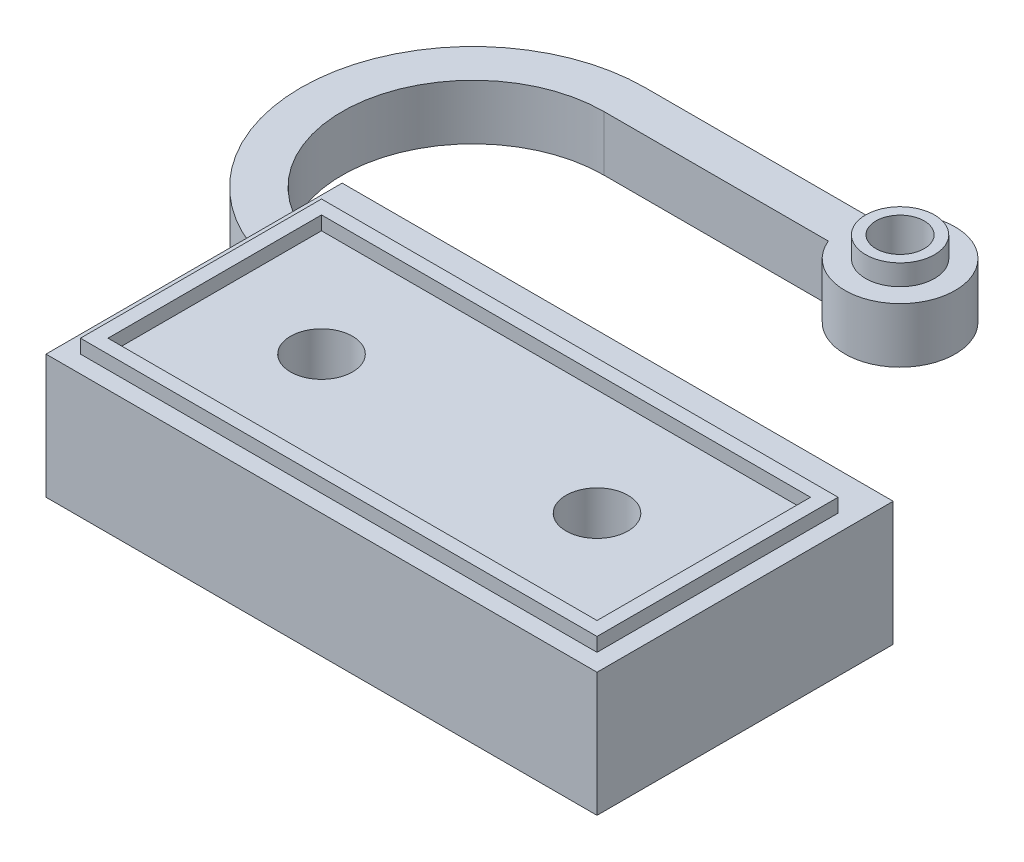
from build123d import *

# Parameters (mm, degrees)
SKETCH1_W           = 40
SKETCH1_H           = 21.5
SKETCH1_R           = 2.25
BOSS_EXTRUDE3_DEPTH = 9
SKETCH1_5_R         = 1.75
BOSS_EXTRUDE4_DEPTH = 4
SKETCH2_R           = 2.5
SKETCH2_R_2         = 1.75
BOSS_EXTRUDE5_DEPTH = 1.5
SKETCH3_W           = 37.5
SKETCH3_H           = 17.5
SKETCH3_W_2         = 35.5
SKETCH3_H_2         = 15.5
BOSS_EXTRUDE6_DEPTH = 1


with BuildPart() as part:
    # Sketch1 → Boss-Extrude3 (new body)
    with BuildSketch(Plane(origin=(0, 0, 0), x_dir=(1, 0, 0), z_dir=(0, 1, 0))):
        with Locations((0, 0.75)):
            Rectangle(SKETCH1_W, SKETCH1_H)
        with Locations((10, 0)):
            Circle(SKETCH1_R, mode=Mode.SUBTRACT)
        with Locations((-10, 0)):
            Circle(SKETCH1_R, mode=Mode.SUBTRACT)
    extrude(amount=BOSS_EXTRUDE3_DEPTH)

    # Sketch1_5 → Boss-Extrude4 (add)
    with BuildSketch(Plane(origin=(0, 0, 0), x_dir=(1, 0, 0), z_dir=(0, 1, 0))):
        with BuildLine():
            ThreePointArc((-20, 33.5), (-32.5, 21), (-20, 8.5))
            Line((-20, 8.5), (-20, 10))
            Line((-20, 10), (-20, 11.5))
            ThreePointArc((-20, 11.5), (-29.5, 21), (-20, 30.5))
            Line((-20, 30.5), (-3.708099244, 30.5))
            ThreePointArc((-3.708099244, 30.5), (4, 32), (-3.708099244, 33.5))
            Line((-3.708099244, 33.5), (-20, 33.5))
        make_face()
        with Locations((0, 32)):
            Circle(SKETCH1_5_R, mode=Mode.SUBTRACT)
    extrude(amount=BOSS_EXTRUDE4_DEPTH)

    # Sketch2 → Boss-Extrude5 (add)
    with BuildSketch(Plane(origin=(0, 4, 0), x_dir=(1, 0, 0), z_dir=(0, 1, 0))):
        with Locations((0, 32)):
            Circle(SKETCH2_R)
        with Locations((0, 32)):
            Circle(SKETCH2_R_2, mode=Mode.SUBTRACT)
    extrude(amount=BOSS_EXTRUDE5_DEPTH)

    # Sketch3 → Boss-Extrude6 (add)
    with BuildSketch(Plane(origin=(0, 9, 0), x_dir=(1, 0, 0), z_dir=(0, 1, 0))):
        Rectangle(SKETCH3_W, SKETCH3_H)
        Rectangle(SKETCH3_W_2, SKETCH3_H_2, mode=Mode.SUBTRACT)
    extrude(amount=BOSS_EXTRUDE6_DEPTH)


solid = part.part
